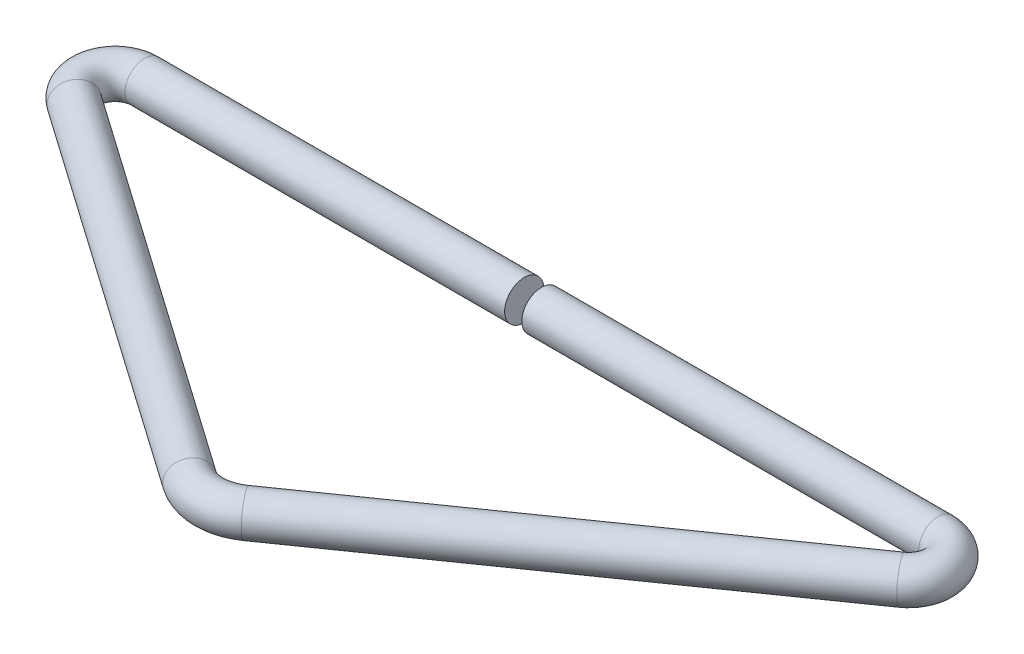
from build123d import *

# Parameters (mm, degrees)
SKETCH_2_R = 2


with BuildPart() as part:
    # 扫描2: sweep along a path in 草图1
    with BuildLine(Plane(origin=(0, 0, 0), x_dir=(1, 0, 0), z_dir=(0, 1, 0))) as sweep_2_path:
        Line((0, 0), (40.485215593, 0))
        ThreePointArc((40.485215593, 0), (43.346366445, -2.097882601), (42.205944902, -5.457456133))
        Line((42.205944902, -5.457456133), (2.867882182, -33.002264188))
        ThreePointArc((2.867882182, -33.002264188), (0, -33.906503967), (-2.867882182, -33.002264188))
        Line((-2.867882182, -33.002264188), (-42.205944902, -5.457456133))
        ThreePointArc((-42.205944902, -5.457456133), (-43.346366445, -2.097882601), (-40.485215593, 0))
        Line((-40.485215593, 0), (-1.754392689, 0))
    # 草图2 → 扫描2 (sweep)
    with BuildSketch(Plane(origin=(0, 0, 0), x_dir=(0, 0, -1), z_dir=(1, 0, 0))):
        Circle(SKETCH_2_R)
    sweep(path=sweep_2_path.line)


solid = part.part
